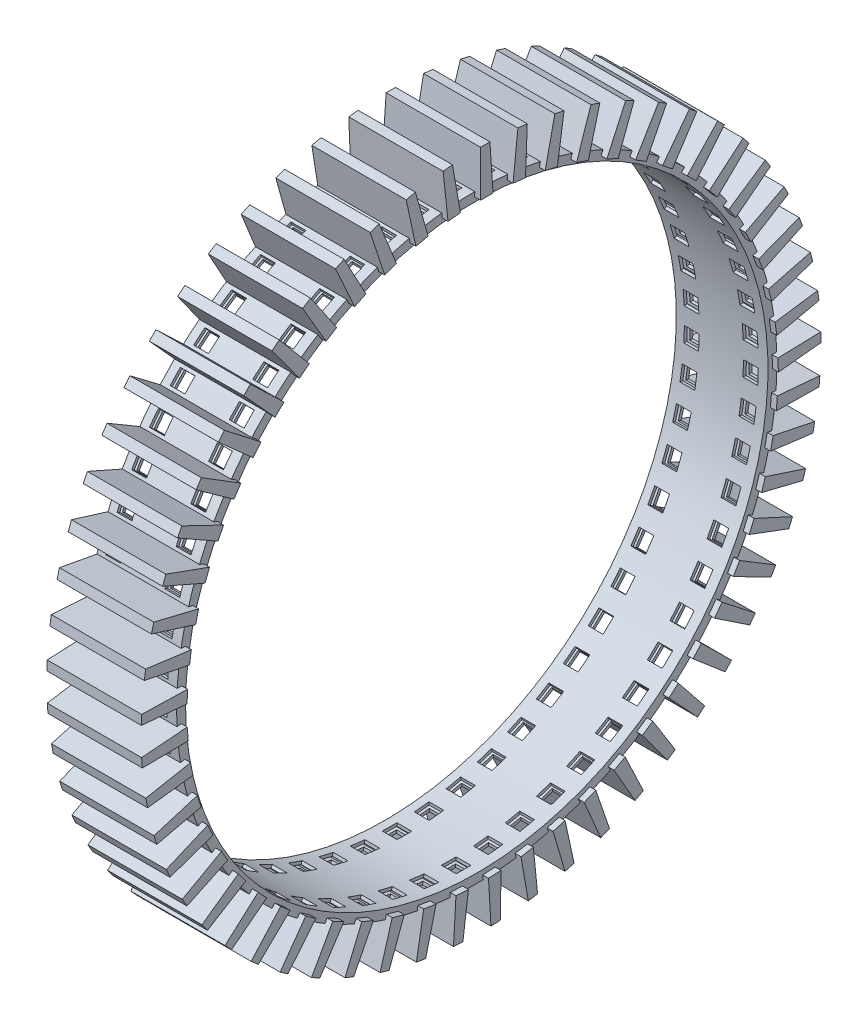
from build123d import *

# Parameters (mm, degrees)
SKETCH3_W           = 31
SKETCH3_H           = 3
SKETCH3_W_2         = 29
SKETCH3_H_2         = 1
SKETCH8_W           = 5.001579668
SKETCH8_H           = 4.981788187
CUT_EXTRUDE7_DEPTH  = 50
CIRPATTERN3_COUNT   = 57
SKETCH11_W          = 32.982916847
SKETCH11_H          = 4.232790807
BOSS_EXTRUDE3_DEPTH = 15
BOSS_EXTRUDE3_TAPER = 2
CIRPATTERN4_COUNT   = 57


with BuildPart() as part:
    # Sketch3 → Revolve-Thin1 (revolve)
    with BuildSketch(Plane.XY, mode=Mode.PRIVATE) as revolve_thin1_sk:
        with Locations((-1.666666667, 100.029)):
            Rectangle(SKETCH3_W, SKETCH3_H)
        with Locations((-1.666666667, 100.029)):
            Rectangle(SKETCH3_W_2, SKETCH3_H_2, mode=Mode.SUBTRACT)
    revolve(revolve_thin1_sk.sketch.rotate(Axis((55.719496505, 0, 0), (-1, 0, 0)), 270), axis=Axis((55.719496505, 0, 0), (-1, 0, 0)))

    # Sketch8 → Cut-Extrude7 (cut)
    with BuildSketch(Plane(origin=(0, 120, 0), x_dir=(-1, 0, 0), z_dir=(0, -1, 0))):
        with Locations((-8.060803486, -4.206157572)):
            Rectangle(SKETCH8_W, SKETCH8_H)
        with Locations((11.94006753, -4.206157572)):
            Rectangle(SKETCH8_W, SKETCH8_H)
    cut_extrude7 = extrude(amount=CUT_EXTRUDE7_DEPTH, mode=Mode.SUBTRACT)

    # CirPattern3: Cut-Extrude7 ×57 about axis
    cirpattern3_axis = Axis((0, 0, 0), (1, 0, 0))
    for i in range(1, CIRPATTERN3_COUNT):
        add(cut_extrude7.rotate(cirpattern3_axis, i * 360 / CIRPATTERN3_COUNT), mode=Mode.SUBTRACT)

    # Sketch11 → Boss-Extrude3 (add)
    with BuildSketch(Plane(origin=(0, 100, 0), x_dir=(1, 0, 0), z_dir=(0, 1, 0))):
        with Locations((-0.675208244, 1.403761667)):
            Rectangle(SKETCH11_W, SKETCH11_H)
    boss_extrude3 = extrude(amount=BOSS_EXTRUDE3_DEPTH, taper=BOSS_EXTRUDE3_TAPER)

    # CirPattern4: Boss-Extrude3 ×57 about axis
    cirpattern4_axis = Axis((0, 0, 0), (1, 0, 0))
    for i in range(1, CIRPATTERN4_COUNT):
        add(boss_extrude3.rotate(cirpattern4_axis, i * 360 / CIRPATTERN4_COUNT))


solid = part.part
